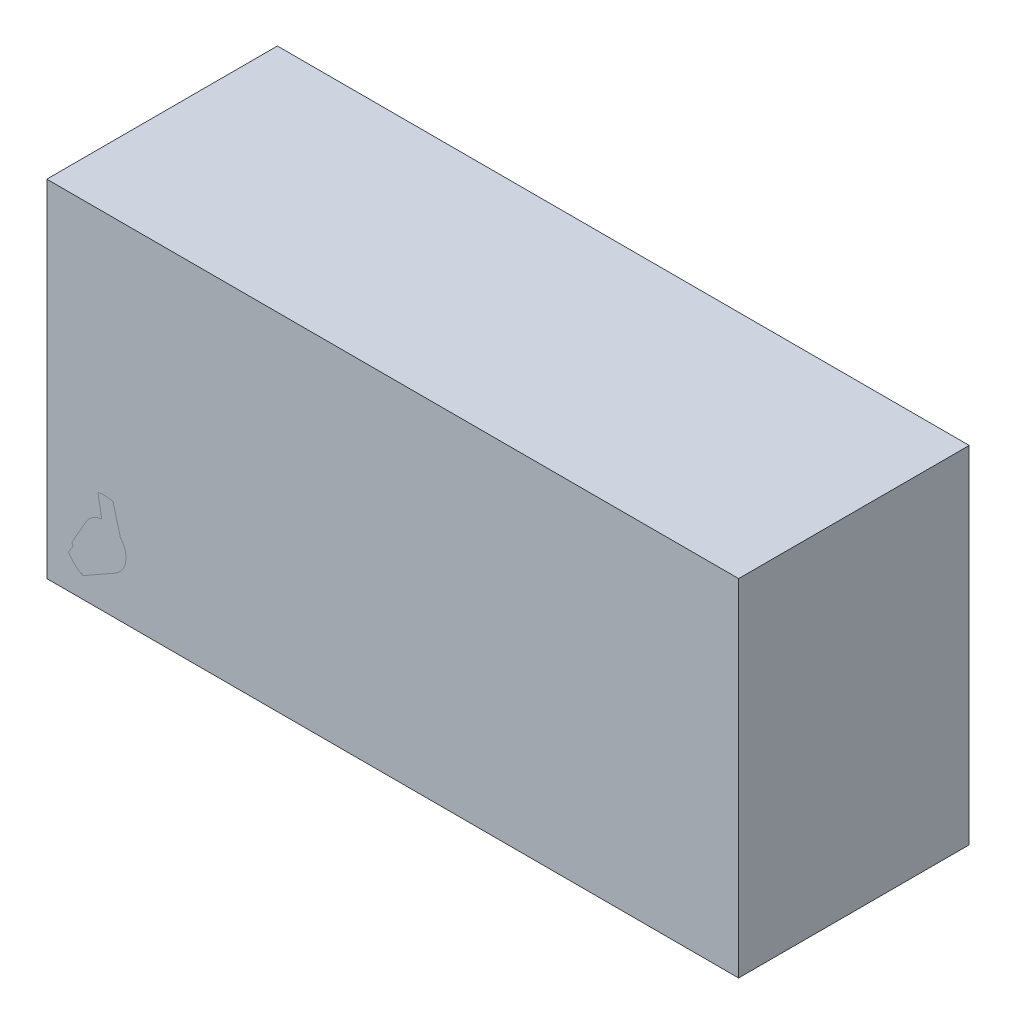
from build123d import *

# Parameters (mm, degrees)
SKETCH1_W           = 152.4
SKETCH1_H           = 76.2
BOSS_EXTRUDE1_DEPTH = 50.8
SKETCH2_R           = 4.7625
CUT_EXTRUDE1_DEPTH  = 12.7
SKETCH3_R           = 4.7625
CUT_EXTRUDE2_DEPTH  = 12.7
SKETCH4_R           = 9.525
BOSS_EXTRUDE2_DEPTH = 12.7


with BuildPart() as part:
    # Sketch1 → Boss-Extrude1 (new body)
    with BuildSketch(Plane.XY):
        Rectangle(SKETCH1_W, SKETCH1_H)
    extrude(amount=BOSS_EXTRUDE1_DEPTH)

    # Sketch2 → Cut-Extrude1 (cut)
    with BuildSketch(Plane.XY.offset(50.8)):
        with Locations((-63.5, -25.4)):
            Circle(SKETCH2_R)
    extrude(amount=-CUT_EXTRUDE1_DEPTH, mode=Mode.SUBTRACT)

    # Sketch3 → Cut-Extrude2 (cut)
    with BuildSketch(Plane(origin=(0, 0, 0), x_dir=(-1, 0, 0), z_dir=(0, 0, -1))):
        with Locations((63.5, 25.4)):
            Circle(SKETCH3_R)
        with Locations((-63.5, 25.4)):
            Circle(SKETCH3_R)
    extrude(amount=-CUT_EXTRUDE2_DEPTH, mode=Mode.SUBTRACT)


with BuildPart() as body_2:
    # Sketch4 → Boss-Extrude2 (new body)
    with BuildSketch(Plane.XY.offset(50.8)):
        with Locations((-63.5, -25.4)):
            Circle(SKETCH4_R)
    extrude(amount=-BOSS_EXTRUDE2_DEPTH)


solid = Compound([part.part, body_2.part])
